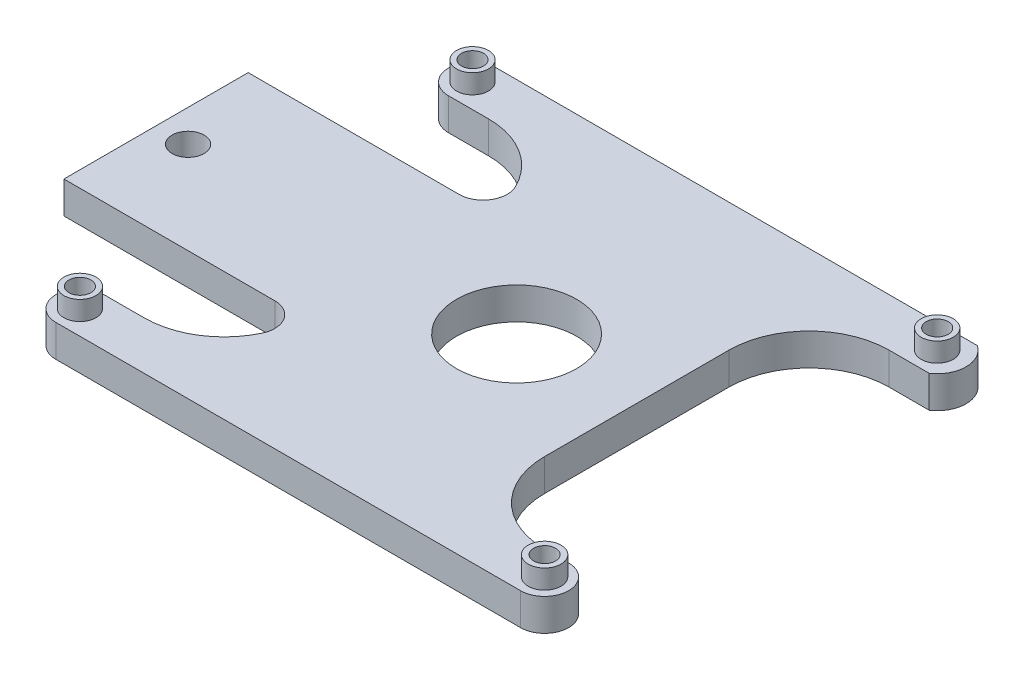
from build123d import *

# Parameters (mm, degrees)
SKETCH2_R           = 1.375
SKETCH2_R_2         = 7.5
BOSS_EXTRUDE1_DEPTH = 4
SKETCH3_R           = 2
CUT_EXTRUDE1_DEPTH  = 10
SKETCH7_R           = 1.995105634
SKETCH7_R_2         = 1.375
SKETCH7_R_3         = 2.001880143
SKETCH7_R_4         = 2.050219115
SKETCH7_R_5         = 2.002328612
BOSS_EXTRUDE2_DEPTH = 2.4


with BuildPart() as part:
    # Sketch2 → Boss-Extrude1 (new body)
    with BuildSketch(Plane(origin=(0, 0, 0), x_dir=(1, 0, 0), z_dir=(0, 1, 0))):
        with BuildLine():
            Line((43.240356283, 42.558742845), (-16.759643717, 42.558742845))
            ThreePointArc((-16.759643717, 42.558742845), (-19.759643717, 39.558742845), (-16.759643717, 36.558742845))
            Line((-16.759643717, 36.558742845), (-11.759643717, 36.558742845))
            ThreePointArc((-11.759643717, 36.558742845), (-6.414418879, 35.010285392), (-2.724564688, 30.84445713))
            ThreePointArc((-2.724564688, 30.84445713), (-2.899625633, 27.955175393), (-5.435088397, 26.558742845))
            Line((-5.435088397, 26.558742845), (-28.759643717, 26.558742845))
            Line((-28.759643717, 26.558742845), (-31.759643717, 26.558742845))
            Line((-31.759643717, 26.558742845), (-31.759643717, 23.558742845))
            Line((-31.759643717, 23.558742845), (-31.759643717, 6.558742845))
            Line((-31.759643717, 6.558742845), (-31.759643717, 3.558742845))
            Line((-31.759643717, 3.558742845), (-28.759643717, 3.558742845))
            Line((-28.759643717, 3.558742845), (-5.435088397, 3.558742845))
            ThreePointArc((-5.435088397, 3.558742845), (-2.899625633, 2.162310296), (-2.724564688, -0.726971441))
            ThreePointArc((-2.724564688, -0.726971441), (-6.414418879, -4.892799703), (-11.759643717, -6.441257155))
            Line((-11.759643717, -6.441257155), (-16.759643717, -6.441257155))
            ThreePointArc((-16.759643717, -6.441257155), (-19.759643717, -9.441257155), (-16.759643717, -12.441257155))
            Line((-16.759643717, -12.441257155), (41.240356283, -12.441257155))
            ThreePointArc((41.240356283, -12.441257155), (44.240356283, -9.441257155), (41.240356283, -6.441257155))
            Line((41.240356283, -6.441257155), (38.240356283, -6.441257155))
            ThreePointArc((38.240356283, -6.441257155), (31.169288471, -3.512324967), (28.240356283, 3.558742845))
            Line((28.240356283, 3.558742845), (28.240356283, 26.558742845))
            ThreePointArc((28.240356283, 26.558742845), (31.169288471, 33.629810657), (38.240356283, 36.558742845))
            Line((38.240356283, 36.558742845), (43.240356283, 36.558742845))
            ThreePointArc((43.240356283, 36.558742845), (44.845907558, 39.558742845), (43.240356283, 42.558742845))
        make_face()
        with Locations((-16.759643717, -9.441257155)):
            Circle(SKETCH2_R, mode=Mode.SUBTRACT)
        with Locations((41.240356283, -9.441257155)):
            Circle(SKETCH2_R, mode=Mode.SUBTRACT)
        with Locations((13.240356283, 15.058742845)):
            Circle(SKETCH2_R_2, mode=Mode.SUBTRACT)
        with Locations((-16.759643717, 39.558742845)):
            Circle(SKETCH2_R, mode=Mode.SUBTRACT)
        with Locations((41.240356283, 39.558742845)):
            Circle(SKETCH2_R, mode=Mode.SUBTRACT)
    extrude(amount=BOSS_EXTRUDE1_DEPTH)

    # Sketch3 → Cut-Extrude1 (cut)
    with BuildSketch(Plane(origin=(0, 4, 0), x_dir=(1, 0, 0), z_dir=(0, 1, 0))):
        with Locations((-27.759643717, 15.058742845)):
            Circle(SKETCH3_R)
    extrude(amount=-CUT_EXTRUDE1_DEPTH, mode=Mode.SUBTRACT)

    # Sketch7 → Boss-Extrude2 (add)
    with BuildSketch(Plane(origin=(0, 4, 0), x_dir=(1, 0, 0), z_dir=(0, 1, 0))):
        with Locations((-16.759643717, 39.558742845)):
            Circle(SKETCH7_R)
        with Locations((-16.759643717, 39.558742845)):
            Circle(SKETCH7_R_2, mode=Mode.SUBTRACT)
        with Locations((-16.759643717, -9.441257155)):
            Circle(SKETCH7_R_3)
        with Locations((-16.759643717, -9.441257155)):
            Circle(SKETCH7_R_2, mode=Mode.SUBTRACT)
        with Locations((41.240356283, -9.441257155)):
            Circle(SKETCH7_R_4)
        with Locations((41.240356283, -9.441257155)):
            Circle(SKETCH7_R_2, mode=Mode.SUBTRACT)
        with Locations((41.240356283, 39.558742845)):
            Circle(SKETCH7_R_5)
        with Locations((41.240356283, 39.558742845)):
            Circle(SKETCH7_R_2, mode=Mode.SUBTRACT)
    extrude(amount=BOSS_EXTRUDE2_DEPTH)


solid = part.part
